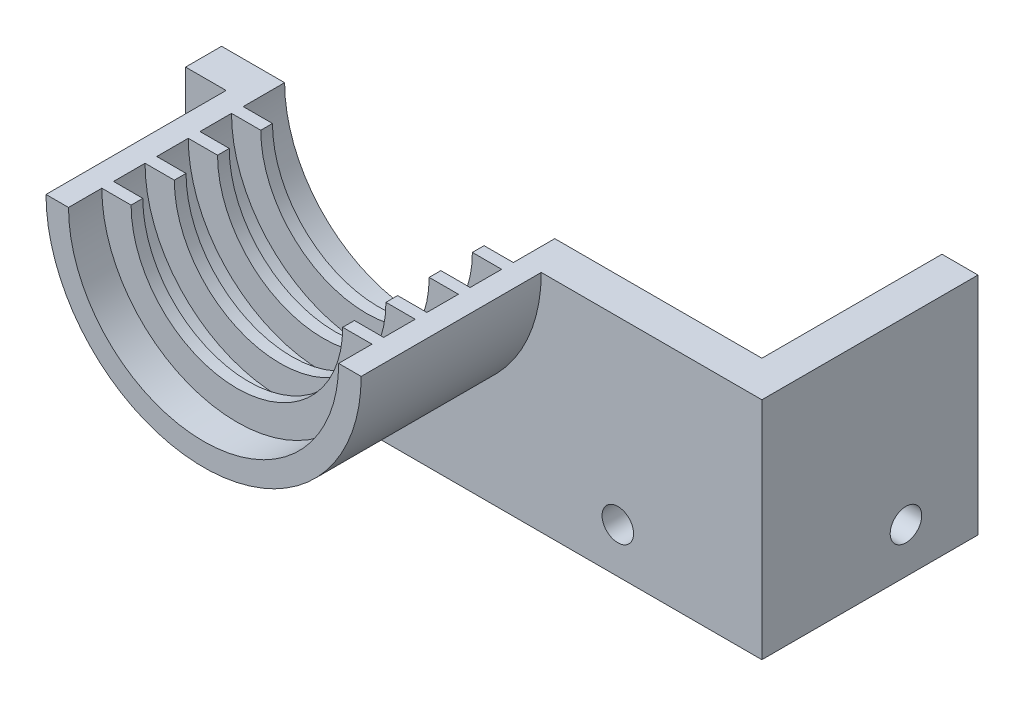
from build123d import *

# Parameters (mm, degrees)
SKETCH1_W            = 66
SKETCH1_H            = 33
BOSS_EXTRUDE1_DEPTH  = 4
CUT_EXTRUDE1_DEPTH   = 5
BOSS_EXTRUDE2_DEPTH  = 20
BOSS_EXTRUDE3_DEPTH  = 1.3
BOSS_EXTRUDE4_DEPTH  = 1.3
BOSS_EXTRUDE5_DEPTH  = 1.3
BOSS_EXTRUDE6_DEPTH  = 1.3
SKETCH11_W           = 66
SKETCH11_H           = 8
CUT_EXTRUDE4_DEPTH   = 10
SKETCH13_W           = 4
SKETCH13_H           = 25
BOSS_EXTRUDE7_DEPTH  = 5
SKETCH14_W           = 4
SKETCH14_H           = 25
BOSS_EXTRUDE8_DEPTH  = 8
SKETCH16_R           = 1.75
CUT_EXTRUDE5_DEPTH   = 12
SKETCH17_R           = 1.75
CUT_EXTRUDE8_DEPTH   = 12
SKETCH18_W           = 4
SKETCH18_H           = 25
CUT_EXTRUDE9_DEPTH   = 3
SKETCH19_W           = 4
SKETCH19_H           = 25
BOSS_EXTRUDE10_DEPTH = 4
SKETCH20_W           = 4
SKETCH20_H           = 25
BOSS_EXTRUDE11_DEPTH = 20
SKETCH21_R           = 1.75
CUT_EXTRUDE10_DEPTH  = 20
SKETCH22_W           = 16
SKETCH22_H           = 25
CUT_EXTRUDE11_DEPTH  = 25


with BuildPart() as part:
    # Sketch1 → Boss-Extrude1 (new body)
    with BuildSketch(Plane.XY):
        with Locations((33, 16.5)):
            Rectangle(SKETCH1_W, SKETCH1_H)
    extrude(amount=BOSS_EXTRUDE1_DEPTH)

    # Sketch2 → Cut-Extrude1 (cut, through all)
    with BuildSketch(Plane.XY.offset(4)):
        with BuildLine():
            Line((18, 33), (48, 33))
            ThreePointArc((48, 33), (33, 18), (18, 33))
        make_face()
    extrude(amount=-CUT_EXTRUDE1_DEPTH, mode=Mode.SUBTRACT)

    # Sketch3 → Boss-Extrude2 (add)
    with BuildSketch(Plane.XY.offset(4)):
        with BuildLine():
            Line((18, 33), (15.5, 33))
            ThreePointArc((15.5, 33), (33, 15.5), (50.5, 33))
            Line((50.5, 33), (48, 33))
            ThreePointArc((48, 33), (33, 18), (18, 33))
        make_face()
    extrude(amount=BOSS_EXTRUDE2_DEPTH)

    # Sketch5 → Boss-Extrude3 (add)
    with BuildSketch(Plane.XY.offset(4.6)):
        with BuildLine():
            Line((18, 33), (21.25, 33))
            ThreePointArc((21.25, 33), (33, 21.25), (44.75, 33))
            Line((44.75, 33), (48, 33))
            ThreePointArc((48, 33), (33, 18), (18, 33))
        make_face()
    extrude(amount=BOSS_EXTRUDE3_DEPTH)

    # Sketch6 → Boss-Extrude4 (add)
    with BuildSketch(Plane.XY.offset(9.4)):
        with BuildLine():
            Line((18, 33), (21.25, 33))
            ThreePointArc((21.25, 33), (33, 21.25), (44.75, 33))
            Line((44.75, 33), (48, 33))
            ThreePointArc((48, 33), (33, 18), (18, 33))
        make_face()
    extrude(amount=BOSS_EXTRUDE4_DEPTH)

    # Sketch7 → Boss-Extrude5 (add)
    with BuildSketch(Plane.XY.offset(14.2)):
        with BuildLine():
            Line((18, 33), (21.25, 33))
            ThreePointArc((21.25, 33), (33, 21.25), (44.75, 33))
            Line((44.75, 33), (48, 33))
            ThreePointArc((48, 33), (33, 18), (18, 33))
        make_face()
    extrude(amount=BOSS_EXTRUDE5_DEPTH)

    # Sketch8 → Boss-Extrude6 (add)
    with BuildSketch(Plane.XY.offset(19)):
        with BuildLine():
            Line((18, 33), (21.25, 33))
            ThreePointArc((21.25, 33), (33, 21.25), (44.75, 33))
            Line((44.75, 33), (48, 33))
            ThreePointArc((48, 33), (33, 18), (18, 33))
        make_face()
    extrude(amount=BOSS_EXTRUDE6_DEPTH)

    # Sketch11 → Cut-Extrude4 (cut)
    with BuildSketch(Plane.XY.offset(4)):
        with Locations((33, 4)):
            Rectangle(SKETCH11_W, SKETCH11_H)
    extrude(amount=-CUT_EXTRUDE4_DEPTH, mode=Mode.SUBTRACT)

    # Sketch13 → Boss-Extrude7 (add)
    with BuildSketch(Plane.ZY):
        with Locations((2, 20.5)):
            Rectangle(SKETCH13_W, SKETCH13_H)
    extrude(amount=BOSS_EXTRUDE7_DEPTH)

    # Sketch14 → Boss-Extrude8 (add)
    with BuildSketch(Plane(origin=(66, 0, 0), x_dir=(0, 0, -1), z_dir=(1, 0, 0))):
        with Locations((-2, 20.5)):
            Rectangle(SKETCH14_W, SKETCH14_H)
    extrude(amount=BOSS_EXTRUDE8_DEPTH)

    # Sketch16 → Cut-Extrude5 (cut)
    with BuildSketch(Plane(origin=(74, 0, 0), x_dir=(0, 0, -1), z_dir=(1, 0, 0))):
        with Locations((14, 13)):
            Circle(SKETCH16_R)
    extrude(amount=-CUT_EXTRUDE5_DEPTH, mode=Mode.SUBTRACT)

    # Sketch17 → Cut-Extrude8 (cut)
    with BuildSketch(Plane.XY.offset(4)):
        with Locations((59, 13)):
            Circle(SKETCH17_R)
    extrude(amount=-CUT_EXTRUDE8_DEPTH, mode=Mode.SUBTRACT)

    # Sketch18 → Cut-Extrude9 (cut)
    with BuildSketch(Plane(origin=(74, 0, 0), x_dir=(0, 0, -1), z_dir=(1, 0, 0))):
        with Locations((-2, 20.5)):
            Rectangle(SKETCH18_W, SKETCH18_H)
    extrude(amount=-CUT_EXTRUDE9_DEPTH, mode=Mode.SUBTRACT)

    # Sketch19 → Boss-Extrude10 (add)
    with BuildSketch(Plane(origin=(71, 0, 0), x_dir=(0, 0, -1), z_dir=(1, 0, 0))):
        with Locations((-2, 20.5)):
            Rectangle(SKETCH19_W, SKETCH19_H)
    extrude(amount=BOSS_EXTRUDE10_DEPTH)

    # Sketch20 → Boss-Extrude11 (add)
    with BuildSketch(Plane(origin=(0, 0, 0), x_dir=(-1, 0, 0), z_dir=(0, 0, -1))):
        with Locations((-73, 20.5)):
            Rectangle(SKETCH20_W, SKETCH20_H)
    extrude(amount=BOSS_EXTRUDE11_DEPTH)

    # Sketch21 → Cut-Extrude10 (cut)
    with BuildSketch(Plane(origin=(75, 0, 0), x_dir=(0, 0, -1), z_dir=(1, 0, 0))):
        with Locations((12, 13)):
            Circle(SKETCH21_R)
    extrude(amount=-CUT_EXTRUDE10_DEPTH, mode=Mode.SUBTRACT)

    # Sketch22 → Cut-Extrude11 (cut, through all)
    with BuildSketch(Plane.XY.offset(4)):
        with Locations((3, 20.5)):
            Rectangle(SKETCH22_W, SKETCH22_H)
    extrude(amount=-CUT_EXTRUDE11_DEPTH, mode=Mode.SUBTRACT)


solid = part.part
